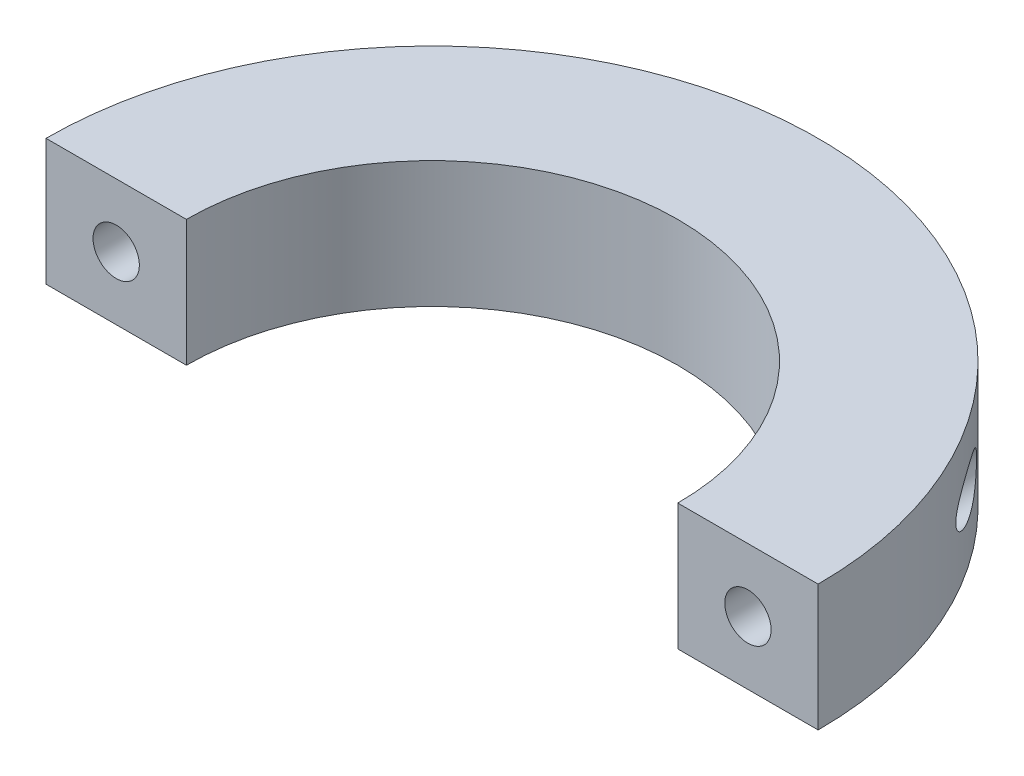
from build123d import *

# Parameters (mm, degrees)
BOSS_EXTRUDE1_DEPTH         = 4.5
TAP_DRILL_FOR_M4X0_7_TAP1_D = 3.3


with BuildPart() as part:
    # Sketch1 → Boss-Extrude1 (new body, symmetric)
    with BuildSketch(Plane(origin=(0, 0, 0), x_dir=(1, 0, 0), z_dir=(0, 1, 0))):
        with BuildLine():
            Line((-27.5, 0), (-17.5, 0))
            ThreePointArc((-17.5, 0), (0, 17.5), (17.5, 0))
            Line((17.5, 0), (27.5, 0))
            ThreePointArc((27.5, 0), (0, 27.5), (-27.5, 0))
        make_face()
    extrude(amount=BOSS_EXTRUDE1_DEPTH, both=True)

    # Tap Drill for M4x0.7 Tap1 (through all)
    with Locations(Plane(origin=(22.5, 0, 0), x_dir=(1, 0, 0), z_dir=(0, 0, 1))):
        with Locations((0, 0), (-45, 0)):
            Hole(TAP_DRILL_FOR_M4X0_7_TAP1_D / 2)


solid = part.part
